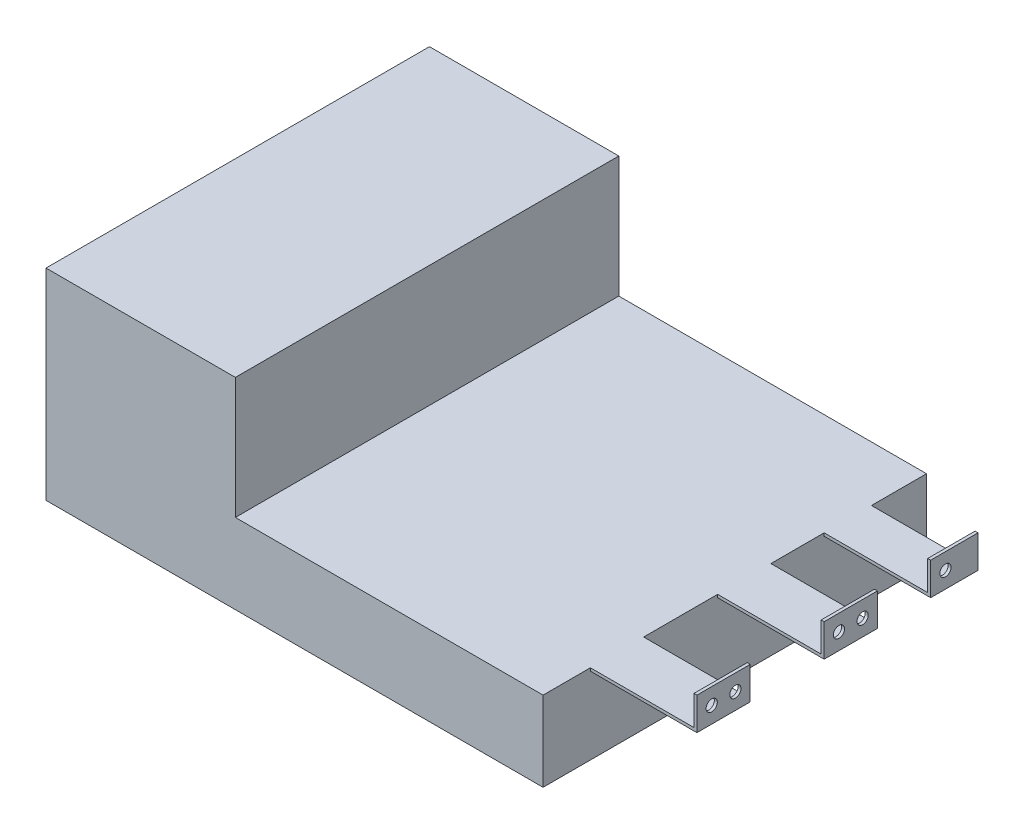
from build123d import *

# Parameters (mm, degrees)
SKETCH1_W               = 101.6
SKETCH1_H               = 205.74
BATTERY_SIDE_DEPTH      = 107.95
SKETCH6_W               = 60.325
SKETCH6_H               = 1.5875
SKETCH6_W_2             = 52.3875
BATTERY_TAB_BASES_DEPTH = 9.525
SKETCH7_W               = 1.5875
SKETCH7_H               = 60.325
SKETCH7_H_2             = 52.3875
BATTERY_TABS_DEPTH      = 25.4
BATTERY_TAB_HOLES_REACH = 113.125
SKETCH8_R               = 3
SKETCH2_W               = 165.1
SKETCH2_H               = 205.74
MOTOR_SIDE_DEPTH        = 42.8625
SKETCH3_W               = 28.575
SKETCH3_H               = 1.5875
SKETCH3_W_2             = 25.4
MOTOR_TAB_BASES_DEPTH   = 57.15
SKETCH4_W               = 1.5875
SKETCH4_H               = 28.575
SKETCH4_H_2             = 25.4
MOTOR_TABS_DEPTH        = 15.875
MOTOR_TAB_HOLES_REACH   = 335.375
SKETCH5_R               = 3


with BuildPart() as part:
    # Sketch1 → Battery Side (new body)
    with BuildSketch(Plane(origin=(0, 0, 0), x_dir=(1, 0, 0), z_dir=(0, 1, 0))):
        with Locations((50.8, 102.87)):
            Rectangle(SKETCH1_W, SKETCH1_H)
    extrude(amount=BATTERY_SIDE_DEPTH)

    # Sketch6 → Battery Tab Bases (add)
    with BuildSketch(Plane.ZY):
        with Locations((-151.765, 38.89375)):
            Rectangle(SKETCH6_W, SKETCH6_H)
        with Locations((-63.65875, 38.89375)):
            Rectangle(SKETCH6_W_2, SKETCH6_H)
    extrude(amount=BATTERY_TAB_BASES_DEPTH)

    # Sketch7 → Battery Tabs (add)
    with BuildSketch(Plane(origin=(0, 39.6875, 0), x_dir=(1, 0, 0), z_dir=(0, 1, 0))):
        with Locations((-8.73125, 151.765)):
            Rectangle(SKETCH7_W, SKETCH7_H)
        with Locations((-8.73125, 63.65875)):
            Rectangle(SKETCH7_W, SKETCH7_H_2)
    extrude(amount=BATTERY_TABS_DEPTH)

    # Sketch8 → Battery Tab Holes (cut, up to next)
    with BuildSketch(Plane.ZY.offset(9.525), mode=Mode.PRIVATE) as battery_tab_holes_sk1:
        with Locations((-172.495098328, 50.0063)):
            Circle(SKETCH8_R)
    battery_tab_holes_tool1 = extrude(battery_tab_holes_sk1.sketch, amount=-BATTERY_TAB_HOLES_REACH, mode=Mode.PRIVATE) & part.part
    add(battery_tab_holes_tool1.solids().sort_by_distance((-9.525, 50.0063, -172.495098))[0], mode=Mode.SUBTRACT)
    # Sketch8 → Battery Tab Holes (cut, up to next)
    with BuildSketch(Plane.ZY.offset(9.525), mode=Mode.PRIVATE) as battery_tab_holes_sk2:
        with Locations((-55.26378475, 50.0063)):
            Circle(SKETCH8_R)
    battery_tab_holes_tool2 = extrude(battery_tab_holes_sk2.sketch, amount=-BATTERY_TAB_HOLES_REACH, mode=Mode.PRIVATE) & part.part
    add(battery_tab_holes_tool2.solids().sort_by_distance((-9.525, 50.0063, -55.263785))[0], mode=Mode.SUBTRACT)

    # Sketch2 → Motor Side (add)
    with BuildSketch(Plane(origin=(0, 0, 0), x_dir=(1, 0, 0), z_dir=(0, 1, 0))):
        with Locations((184.15, 102.87)):
            Rectangle(SKETCH2_W, SKETCH2_H)
    extrude(amount=MOTOR_SIDE_DEPTH)

    # Sketch3 → Motor Tab Bases (add)
    with BuildSketch(Plane(origin=(266.7, 0, 0), x_dir=(0, 0, -1), z_dir=(1, 0, 0))):
        with Locations((39.6875, 42.06875)):
            Rectangle(SKETCH3_W, SKETCH3_H)
        with Locations((107.95, 42.06875)):
            Rectangle(SKETCH3_W, SKETCH3_H)
        with Locations((163.5125, 42.06875)):
            Rectangle(SKETCH3_W_2, SKETCH3_H)
    extrude(amount=MOTOR_TAB_BASES_DEPTH)

    # Sketch4 → Motor Tabs (add)
    with BuildSketch(Plane(origin=(0, 42.8625, 0), x_dir=(1, 0, 0), z_dir=(0, 1, 0))):
        with Locations((323.05625, 39.6875)):
            Rectangle(SKETCH4_W, SKETCH4_H)
        with Locations((323.05625, 107.95)):
            Rectangle(SKETCH4_W, SKETCH4_H)
        with Locations((323.05625, 163.5125)):
            Rectangle(SKETCH4_W, SKETCH4_H_2)
    extrude(amount=MOTOR_TABS_DEPTH)

    # Sketch5 → Motor Tab Holes (cut, up to next)
    with BuildSketch(Plane(origin=(323.85, 0, 0), x_dir=(0, 0, -1), z_dir=(1, 0, 0)), mode=Mode.PRIVATE) as motor_tab_holes_sk1:
        with Locations((33.3375, 50.00625)):
            Circle(SKETCH5_R)
    motor_tab_holes_tool1 = extrude(motor_tab_holes_sk1.sketch, amount=-MOTOR_TAB_HOLES_REACH, mode=Mode.PRIVATE) & part.part
    add(motor_tab_holes_tool1.solids().sort_by_distance((323.85, 50.00625, -33.3375))[0], mode=Mode.SUBTRACT)
    # Sketch5 → Motor Tab Holes (cut, up to next)
    with BuildSketch(Plane(origin=(323.85, 0, 0), x_dir=(0, 0, -1), z_dir=(1, 0, 0)), mode=Mode.PRIVATE) as motor_tab_holes_sk2:
        with Locations((46.0375, 50.00625)):
            Circle(SKETCH5_R)
    motor_tab_holes_tool2 = extrude(motor_tab_holes_sk2.sketch, amount=-MOTOR_TAB_HOLES_REACH, mode=Mode.PRIVATE) & part.part
    add(motor_tab_holes_tool2.solids().sort_by_distance((323.85, 50.00625, -46.0375))[0], mode=Mode.SUBTRACT)
    # Sketch5 → Motor Tab Holes (cut, up to next)
    with BuildSketch(Plane(origin=(323.85, 0, 0), x_dir=(0, 0, -1), z_dir=(1, 0, 0)), mode=Mode.PRIVATE) as motor_tab_holes_sk3:
        with Locations((101.6, 50.00625)):
            Circle(SKETCH5_R)
    motor_tab_holes_tool3 = extrude(motor_tab_holes_sk3.sketch, amount=-MOTOR_TAB_HOLES_REACH, mode=Mode.PRIVATE) & part.part
    add(motor_tab_holes_tool3.solids().sort_by_distance((323.85, 50.00625, -101.6))[0], mode=Mode.SUBTRACT)
    # Sketch5 → Motor Tab Holes (cut, up to next)
    with BuildSketch(Plane(origin=(323.85, 0, 0), x_dir=(0, 0, -1), z_dir=(1, 0, 0)), mode=Mode.PRIVATE) as motor_tab_holes_sk4:
        with Locations((114.3, 50.00625)):
            Circle(SKETCH5_R)
    motor_tab_holes_tool4 = extrude(motor_tab_holes_sk4.sketch, amount=-MOTOR_TAB_HOLES_REACH, mode=Mode.PRIVATE) & part.part
    add(motor_tab_holes_tool4.solids().sort_by_distance((323.85, 50.00625, -114.3))[0], mode=Mode.SUBTRACT)
    # Sketch5 → Motor Tab Holes (cut, up to next)
    with BuildSketch(Plane(origin=(323.85, 0, 0), x_dir=(0, 0, -1), z_dir=(1, 0, 0)), mode=Mode.PRIVATE) as motor_tab_holes_sk5:
        with Locations((158.75, 50.00625)):
            Circle(SKETCH5_R)
    motor_tab_holes_tool5 = extrude(motor_tab_holes_sk5.sketch, amount=-MOTOR_TAB_HOLES_REACH, mode=Mode.PRIVATE) & part.part
    add(motor_tab_holes_tool5.solids().sort_by_distance((323.85, 50.00625, -158.75))[0], mode=Mode.SUBTRACT)


solid = part.part
